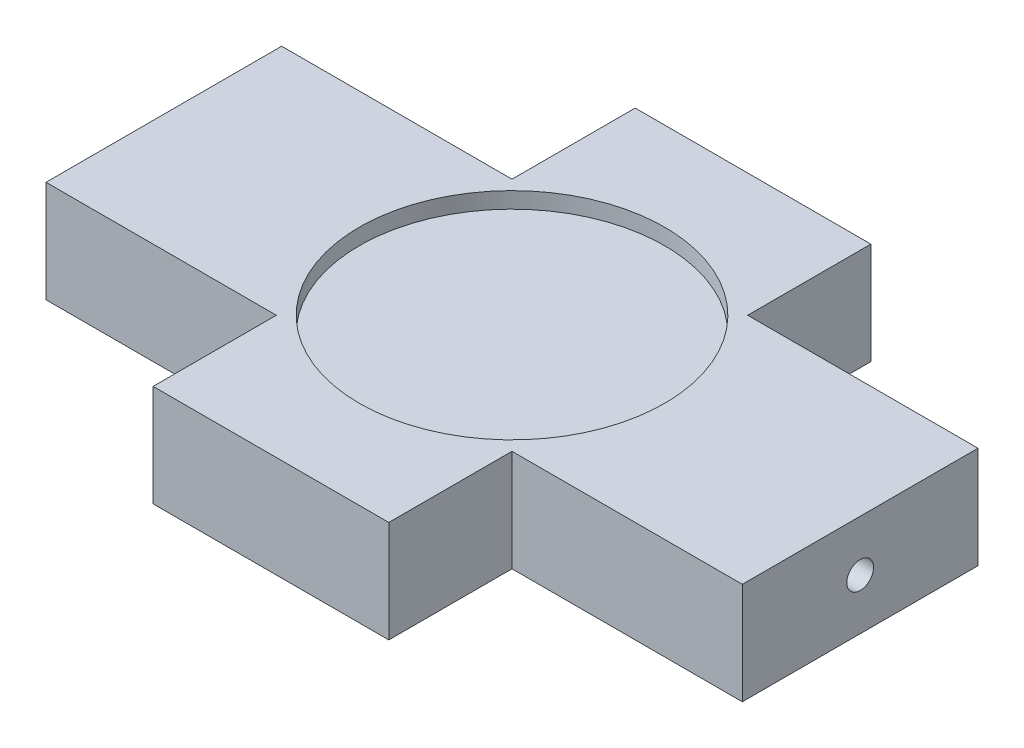
from build123d import *

# Parameters (mm, degrees)
SKETCH1_W           = 90
SKETCH1_H           = 90
BOSS_EXTRUDE1_DEPTH = 19
SKETCH9_W           = 44
SKETCH9_H           = 19
BOSS_EXTRUDE2_DEPTH = 65
SKETCH2_R           = 28.5
CUT_EXTRUDE1_DEPTH  = 3
SKETCH4_W           = 23
SKETCH4_H           = 23
CUT_EXTRUDE3_DEPTH  = 144.391073641
SKETCH11_R          = 2.5
CUT_EXTRUDE4_DEPTH  = 10
CUT_EXTRUDE5_START  = -10
SKETCH12_R          = 2.5
CUT_EXTRUDE5_DEPTH  = 10


with BuildPart() as part:
    # Sketch1 → Boss-Extrude1 (new body)
    with BuildSketch(Plane(origin=(0, 0, 0), x_dir=(1, 0, 0), z_dir=(0, 1, 0))):
        with Locations((45, 45)):
            Rectangle(SKETCH1_W, SKETCH1_H)
    extrude(amount=BOSS_EXTRUDE1_DEPTH)

    # Sketch9 → Boss-Extrude2 (add, symmetric)
    with BuildSketch(Plane(origin=(45, 0, 0), x_dir=(0, 0, -1), z_dir=(1, 0, 0))):
        with Locations((45, 9.5)):
            Rectangle(SKETCH9_W, SKETCH9_H)
    extrude(amount=BOSS_EXTRUDE2_DEPTH, both=True)

    # Sketch2 → Cut-Extrude1 (cut)
    with BuildSketch(Plane(origin=(0, 19, 0), x_dir=(1, 0, 0), z_dir=(0, 1, 0))):
        with Locations((45, 45)):
            Circle(SKETCH2_R)
    extrude(amount=-CUT_EXTRUDE1_DEPTH, mode=Mode.SUBTRACT)

    # Sketch4 → Cut-Extrude3 (cut, through all)
    with BuildSketch(Plane(origin=(0, 19, 0), x_dir=(1, 0, 0), z_dir=(0, 1, 0))):
        with Locations((11.5, 11.5)):
            Rectangle(SKETCH4_W, SKETCH4_H)
        with Locations((11.5, 78.5)):
            Rectangle(SKETCH4_W, SKETCH4_H)
        with Locations((78.5, 78.5)):
            Rectangle(SKETCH4_W, SKETCH4_H)
        with Locations((78.5, 11.5)):
            Rectangle(SKETCH4_W, SKETCH4_H)
    extrude(amount=-CUT_EXTRUDE3_DEPTH, mode=Mode.SUBTRACT)

    # Sketch11 → Cut-Extrude4 (cut)
    with BuildSketch(Plane(origin=(110, 0, 0), x_dir=(0, 0, -1), z_dir=(1, 0, 0))):
        with Locations((45, 9.5)):
            Circle(SKETCH11_R)
    extrude(amount=-CUT_EXTRUDE4_DEPTH, mode=Mode.SUBTRACT)

    # Sketch12 → Cut-Extrude5 (cut)
    with BuildSketch(Plane.ZY.offset(20).offset(CUT_EXTRUDE5_START)):
        with Locations((-45, 9.5)):
            Circle(SKETCH12_R)
    extrude(amount=CUT_EXTRUDE5_DEPTH, mode=Mode.SUBTRACT)


solid = part.part
